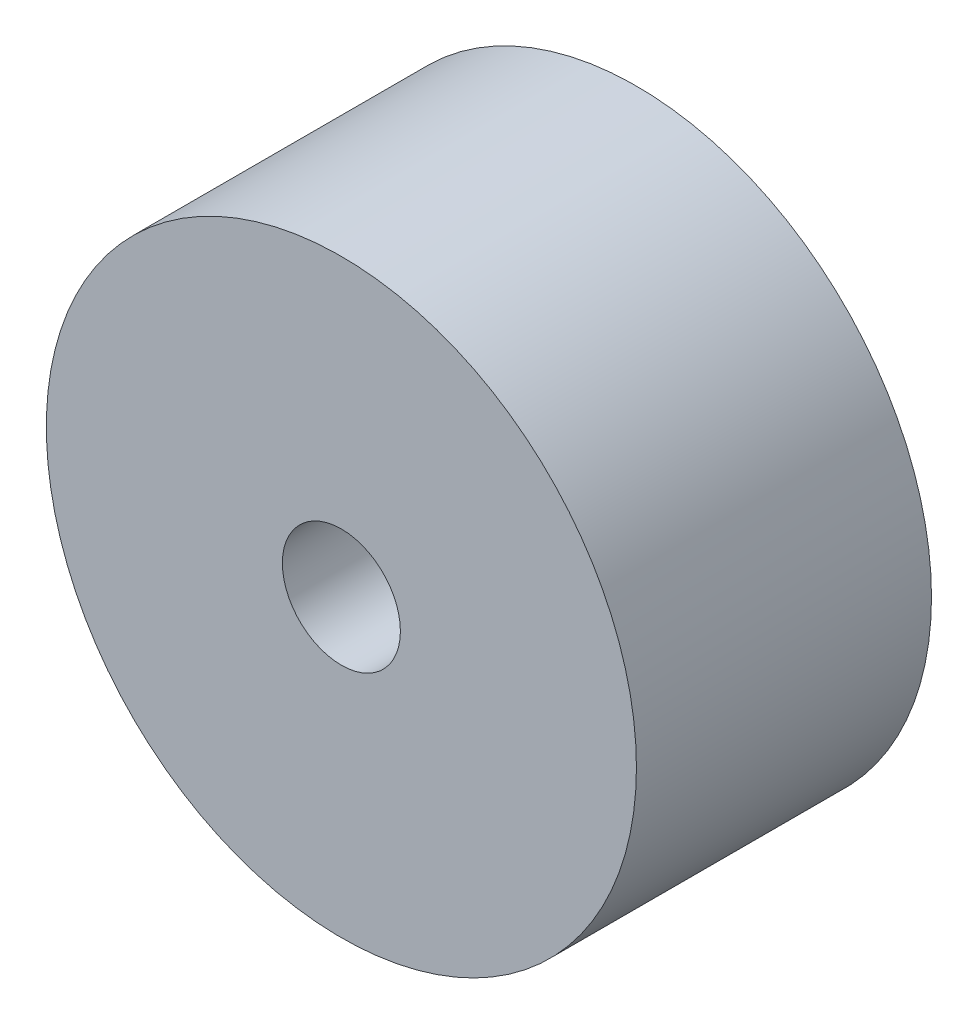
from build123d import *

# Parameters (mm, degrees)
CROQUIS1_R              = 0.5
CROQUIS1_R_2            = 0.1
SALIENTE_EXTRUIR1_DEPTH = 0.5
REDONDEO1_R             = 0.15


with BuildPart() as part:
    # Croquis1 → Saliente-Extruir1 (new body)
    with BuildSketch(Plane.XY):
        Circle(CROQUIS1_R)
        Circle(CROQUIS1_R_2, mode=Mode.SUBTRACT)
    extrude(amount=SALIENTE_EXTRUIR1_DEPTH)

    # Croquis2 → Cortar-Revolución1 (revolve, cut)
    with BuildSketch(Plane(origin=(0, 0, 0), x_dir=(0, 0, -1), z_dir=(1, 0, 0))):
        with BuildLine():
            Line((0, 0), (-0.125, 0))
            ThreePointArc((-0.125, 0), (-0.092326598, -0.153093109), (0, -0.279508497))
            Line((0, -0.279508497), (0, 0))
        make_face()
    revolve(axis=Axis((0, 0, 0), (0, 0, 1)), mode=Mode.SUBTRACT)

    # Redondeo1
    redondeo1_edges = [part.edges().sort_by_distance(p)[0] for p in [
        (-0.070710678, 0.070710678, 0.111420807),
    ]]
    fillet(redondeo1_edges, radius=REDONDEO1_R)


solid = part.part
